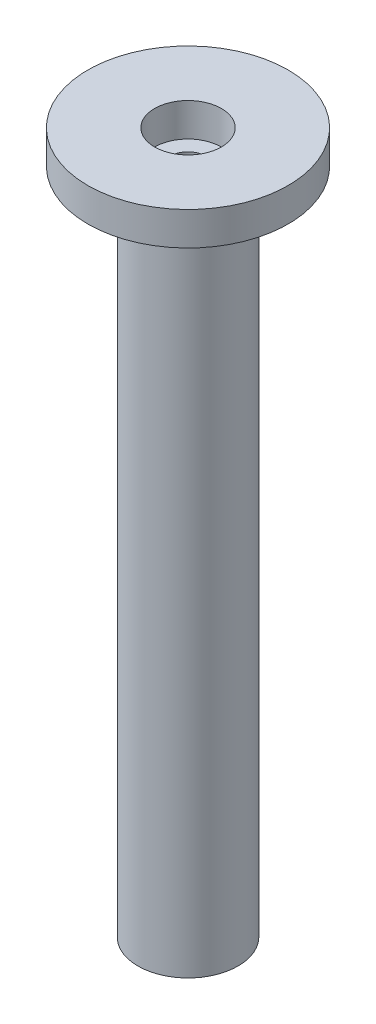
from build123d import *

# Parameters (mm, degrees)
SKETCH1_R           = 9.525
BOSS_EXTRUDE1_DEPTH = 127
SKETCH2_R           = 19.05
BOSS_EXTRUDE2_DEPTH = 6.35
SKETCH3_R           = 6.35
CUT_EXTRUDE1_DEPTH  = 6.35
SKETCH4_R           = 6.35
CUT_EXTRUDE2_DEPTH  = 6.35
SKETCH5_R           = 3.3734375
CUT_EXTRUDE3_DEPTH  = 128


with BuildPart() as part:
    # Sketch1 → Boss-Extrude1 (new body)
    with BuildSketch(Plane(origin=(0, 0, 0), x_dir=(1, 0, 0), z_dir=(0, 1, 0))):
        Circle(SKETCH1_R)
    extrude(amount=BOSS_EXTRUDE1_DEPTH)

    # Sketch2 → Boss-Extrude2 (add)
    with BuildSketch(Plane(origin=(0, 127, 0), x_dir=(1, 0, 0), z_dir=(0, 1, 0))):
        Circle(SKETCH2_R)
    extrude(amount=BOSS_EXTRUDE2_DEPTH)

    # Sketch3 → Cut-Extrude1 (cut)
    with BuildSketch(Plane(origin=(0, 133.35, 0), x_dir=(1, 0, 0), z_dir=(0, 1, 0))):
        Circle(SKETCH3_R)
    extrude(amount=-CUT_EXTRUDE1_DEPTH, mode=Mode.SUBTRACT)

    # Sketch4 → Cut-Extrude2 (cut)
    with BuildSketch(Plane.XZ):
        Circle(SKETCH4_R)
    extrude(amount=-CUT_EXTRUDE2_DEPTH, mode=Mode.SUBTRACT)

    # Sketch5 → Cut-Extrude3 (cut, through all)
    with BuildSketch(Plane.XZ.offset(-6.35)):
        Circle(SKETCH5_R)
    extrude(amount=-CUT_EXTRUDE3_DEPTH, mode=Mode.SUBTRACT)


solid = part.part
